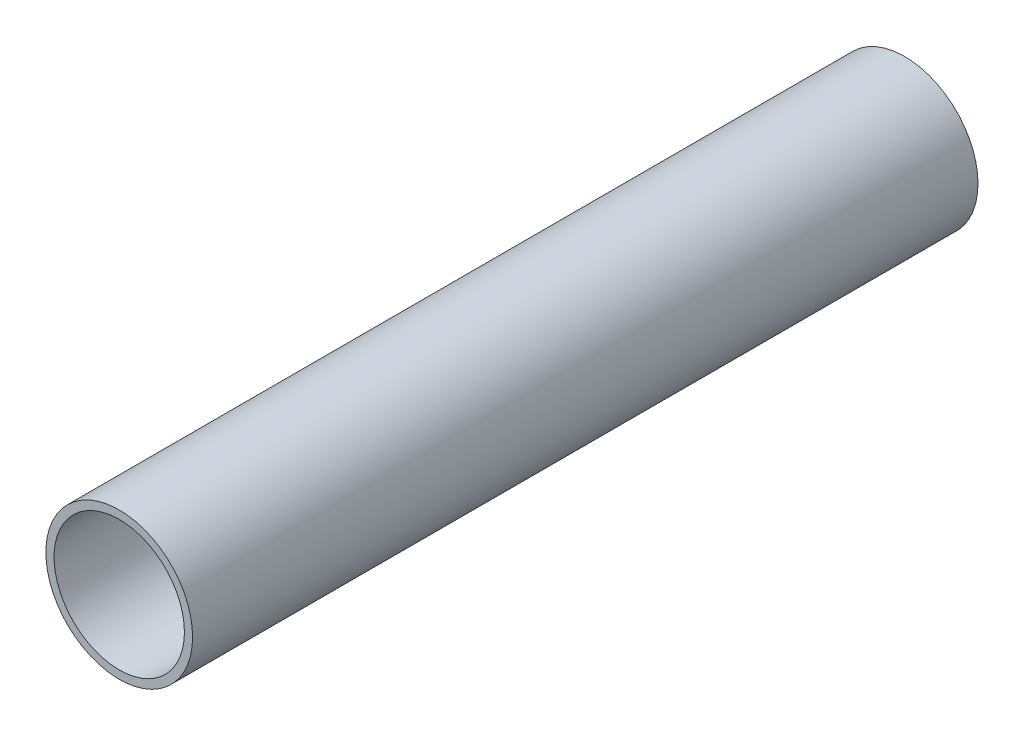
from build123d import *

# Parameters (mm, degrees)
SKETCH1_R           = 56.945
SKETCH1_R_2         = 50.595
BOSS_EXTRUDE1_DEPTH = 609.6


with BuildPart() as part:
    # Sketch1 → Boss-Extrude1 (new body)
    with BuildSketch(Plane.XY):
        Circle(SKETCH1_R)
        Circle(SKETCH1_R_2, mode=Mode.SUBTRACT)
    extrude(amount=BOSS_EXTRUDE1_DEPTH)


solid = part.part
